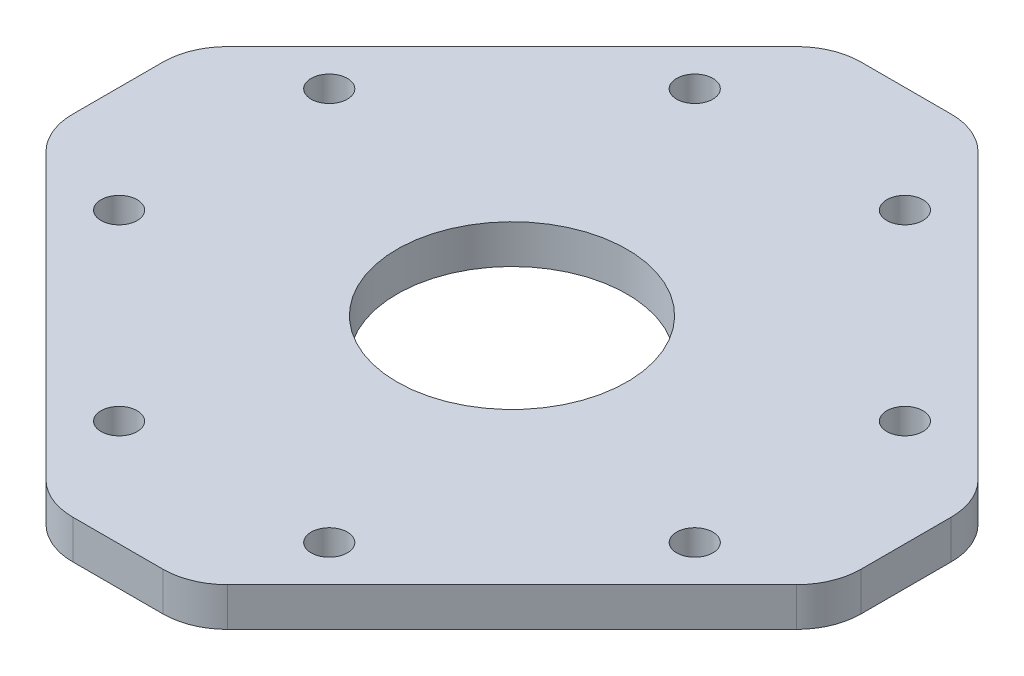
from build123d import *

# Parameters (mm, degrees)
SKETCH1_R           = 8.9
SKETCH1_R_2         = 1.4
BOSS_EXTRUDE1_DEPTH = 3


with BuildPart() as part:
    # Sketch1 → Boss-Extrude1 (new body)
    with BuildSketch(Plane(origin=(0, 0, 0), x_dir=(1, 0, 0), z_dir=(0, 1, 0))):
        with BuildLine():
            Line((3.491378029, 30.5), (-3.491378029, 30.5))
            ThreePointArc((-3.491378029, 30.5), (-5.40479519, 30.119397663), (-7.026911935, 29.035533906))
            Line((-7.026911935, 29.035533906), (-29.035533906, 7.026911935))
            ThreePointArc((-29.035533906, 7.026911935), (-30.119397663, 5.40479519), (-30.5, 3.491378029))
            Line((-30.5, 3.491378029), (-30.5, -3.491378029))
            ThreePointArc((-30.5, -3.491378029), (-30.119397663, -5.40479519), (-29.035533906, -7.026911935))
            Line((-29.035533906, -7.026911935), (-7.026911935, -29.035533906))
            ThreePointArc((-7.026911935, -29.035533906), (-5.40479519, -30.119397663), (-3.491378029, -30.5))
            Line((-3.491378029, -30.5), (3.491378029, -30.5))
            ThreePointArc((3.491378029, -30.5), (5.40479519, -30.119397663), (7.026911935, -29.035533906))
            Line((7.026911935, -29.035533906), (29.035533906, -7.026911935))
            ThreePointArc((29.035533906, -7.026911935), (30.119397663, -5.40479519), (30.5, -3.491378029))
            Line((30.5, -3.491378029), (30.5, 3.491378029))
            ThreePointArc((30.5, 3.491378029), (30.119397663, 5.40479519), (29.035533906, 7.026911935))
            Line((29.035533906, 7.026911935), (7.026911935, 29.035533906))
            ThreePointArc((7.026911935, 29.035533906), (5.40479519, 30.119397663), (3.491378029, 30.5))
        make_face()
        Circle(SKETCH1_R, mode=Mode.SUBTRACT)
        with Locations((8.131727984, -22.273863607)):
            Circle(SKETCH1_R_2, mode=Mode.SUBTRACT)
        with Locations((-8.131727984, -22.273863607)):
            Circle(SKETCH1_R_2, mode=Mode.SUBTRACT)
        with Locations((-22.273863607, -8.131727984)):
            Circle(SKETCH1_R_2, mode=Mode.SUBTRACT)
        with Locations((22.273863607, -8.131727984)):
            Circle(SKETCH1_R_2, mode=Mode.SUBTRACT)
        with Locations((22.273863607, 8.131727984)):
            Circle(SKETCH1_R_2, mode=Mode.SUBTRACT)
        with Locations((8.131727984, 22.273863607)):
            Circle(SKETCH1_R_2, mode=Mode.SUBTRACT)
        with Locations((-8.131727984, 22.273863607)):
            Circle(SKETCH1_R_2, mode=Mode.SUBTRACT)
        with Locations((-22.273863607, 8.131727984)):
            Circle(SKETCH1_R_2, mode=Mode.SUBTRACT)
    extrude(amount=BOSS_EXTRUDE1_DEPTH)


solid = part.part
